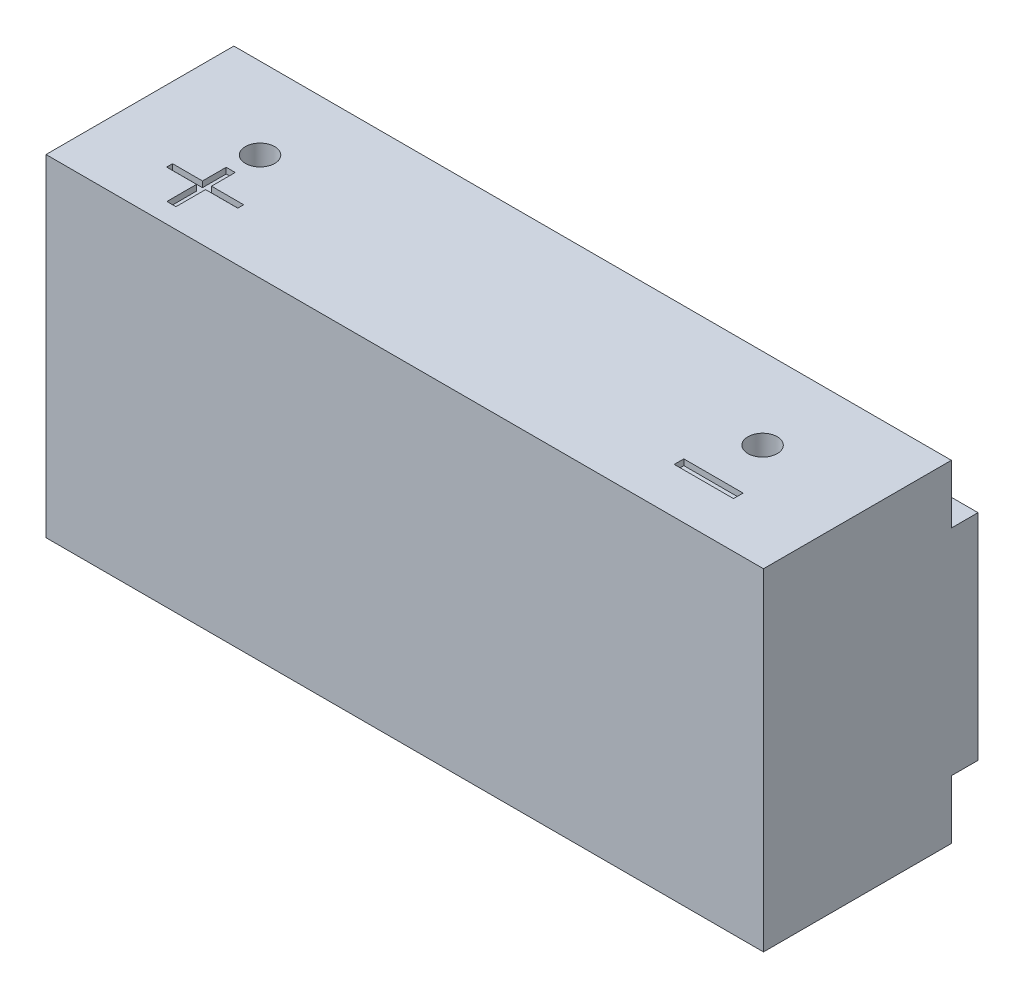
from build123d import *

# Parameters (mm, degrees)
SKETCH1_W           = 310.63946
SKETCH1_H           = 92.869200088
BOSS_EXTRUDE1_DEPTH = 143.6878
SKETCH2_R           = 6.35
CUT_EXTRUDE1_DEPTH  = 144.6878
SKETCH3_W           = 310.82742
SKETCH3_H           = 12.7
CUT_EXTRUDE2_DEPTH  = 25.4
SKETCH4_W           = 25.653918198
SKETCH4_H           = 4.153491518
CUT_EXTRUDE3_DEPTH  = 2.54


with BuildPart() as part:
    # Sketch1 → Boss-Extrude1 (new body)
    with BuildSketch(Plane(origin=(0, 0, 0), x_dir=(1, 0, 0), z_dir=(0, 1, 0))):
        with Locations((155.31973, 46.434600044)):
            Rectangle(SKETCH1_W, SKETCH1_H)
    extrude(amount=BOSS_EXTRUDE1_DEPTH)

    # Sketch2 → Cut-Extrude1 (cut, through all)
    with BuildSketch(Plane(origin=(0, 143.6878, 0), x_dir=(1, 0, 0), z_dir=(0, 1, 0))):
        with Locations((46.5328, 46.14164)):
            Circle(SKETCH2_R)
        with Locations((264.10666, 46.14164)):
            Circle(SKETCH2_R)
    extrude(amount=-CUT_EXTRUDE1_DEPTH, mode=Mode.SUBTRACT)

    # Sketch3 → Cut-Extrude2 (cut)
    with BuildSketch(Plane(origin=(0, 143.6878, 0), x_dir=(1, 0, 0), z_dir=(0, 1, 0))):
        with Locations((155.41371, 87.68842)):
            Rectangle(SKETCH3_W, SKETCH3_H)
    cut_extrude2 = extrude(amount=-CUT_EXTRUDE2_DEPTH, mode=Mode.SUBTRACT)

    # Mirror1: Cut-Extrude2 across plane
    add(cut_extrude2.mirror(Plane.ZX.offset(71.8439)), mode=Mode.SUBTRACT)

    # Sketch4 → Cut-Extrude3 (cut)
    with BuildSketch(Plane(origin=(0, 143.6878, 0), x_dir=(1, 0, 0), z_dir=(0, 1, 0))):
        Polygon((43.786266597, 21.391489422), (43.786266597, 8.564530323), (47.695435084, 8.564530323), (47.695435084, 21.391489422), (61.62184782, 21.391489422), (61.62184782, 23.956881242), (47.695435084, 23.956881242), (47.695435084, 34.218448521), (43.786266597, 34.218448521), (43.786266597, 23.956881242), (30.837145982, 23.956881242), (30.837145982, 21.391489422), align=None)
        with Locations((265.020770675, 21.880135483)):
            Rectangle(SKETCH4_W, SKETCH4_H)
    extrude(amount=-CUT_EXTRUDE3_DEPTH, mode=Mode.SUBTRACT)


solid = part.part
